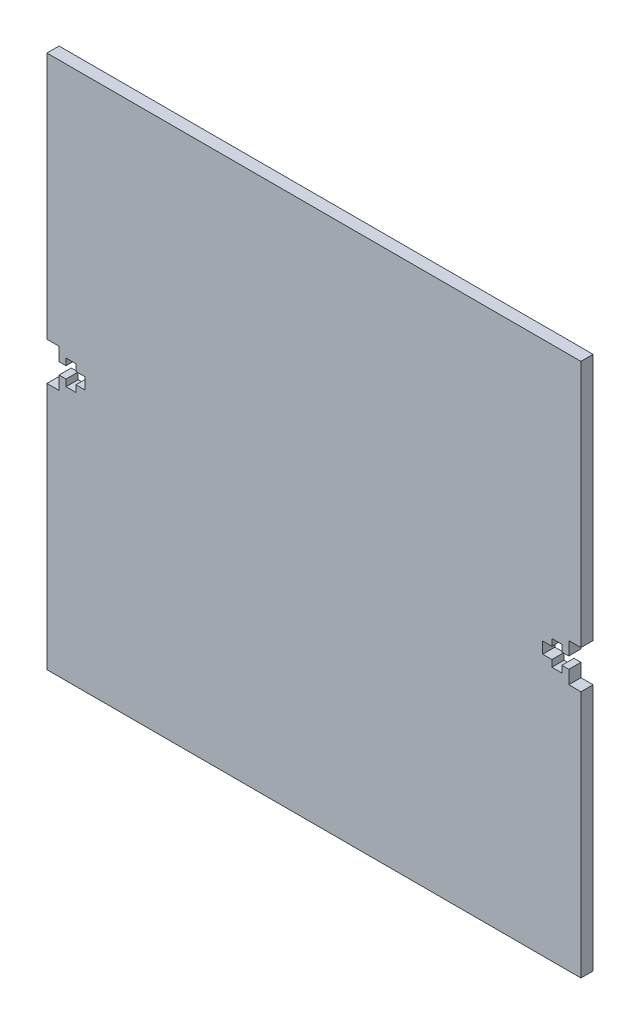
from build123d import *

# Parameters (mm, degrees)
SKETCH1_W           = 139.7
SKETCH1_H           = 139.7
BOSS_EXTRUDE1_DEPTH = 3.18
CUT_EXTRUDE1_DEPTH  = 4.18
CUT_EXTRUDE3_DEPTH  = 10


with BuildPart() as part:
    # Sketch1 → Boss-Extrude1 (new body)
    with BuildSketch(Plane.XY):
        Rectangle(SKETCH1_W, SKETCH1_H)
    extrude(amount=BOSS_EXTRUDE1_DEPTH)

    # Sketch21 → Cut-Extrude1 (cut, through all)
    with BuildSketch(Plane(origin=(-38.395626554, -37.199596717, 0), x_dir=(-1, 0, 0), z_dir=(0, 0, -1))):
        Polygon((28.274373446, 35.699596717), (28.274373446, 32.199596717), (31.454373446, 32.199596717), (31.454373446, 42.199596717), (28.274373446, 42.199596717), (28.274373446, 38.699596717), (26.454373446, 38.699596717), (26.454373446, 40.449596717), (23.854373446, 40.449596717), (23.854373446, 38.699596717), (21.454373446, 38.699596717), (21.454373446, 35.699596717), (23.854373446, 35.699596717), (23.854373446, 33.949596717), (26.454373446, 33.949596717), (26.454373446, 35.699596717), align=None)
    extrude(amount=-CUT_EXTRUDE1_DEPTH, mode=Mode.SUBTRACT)

    # Sketch22 → Cut-Extrude3 (cut)
    with BuildSketch(Plane(origin=(0, 0, 0), x_dir=(-1, 0, 0), z_dir=(0, 0, -1))):
        Polygon((-66.67, -5), (-69.85, -5), (-69.85, 5), (-66.67, 5), (-66.67, 1.5), (-64.85, 1.5), (-64.85, 3.25), (-62.25, 3.25), (-62.25, 1.5), (-59.85, 1.5), (-59.85, -1.5), (-62.25, -1.5), (-62.25, -3.25), (-64.85, -3.25), (-64.85, -1.5), (-66.67, -1.5), align=None)
    extrude(amount=-CUT_EXTRUDE3_DEPTH, mode=Mode.SUBTRACT)


solid = part.part
